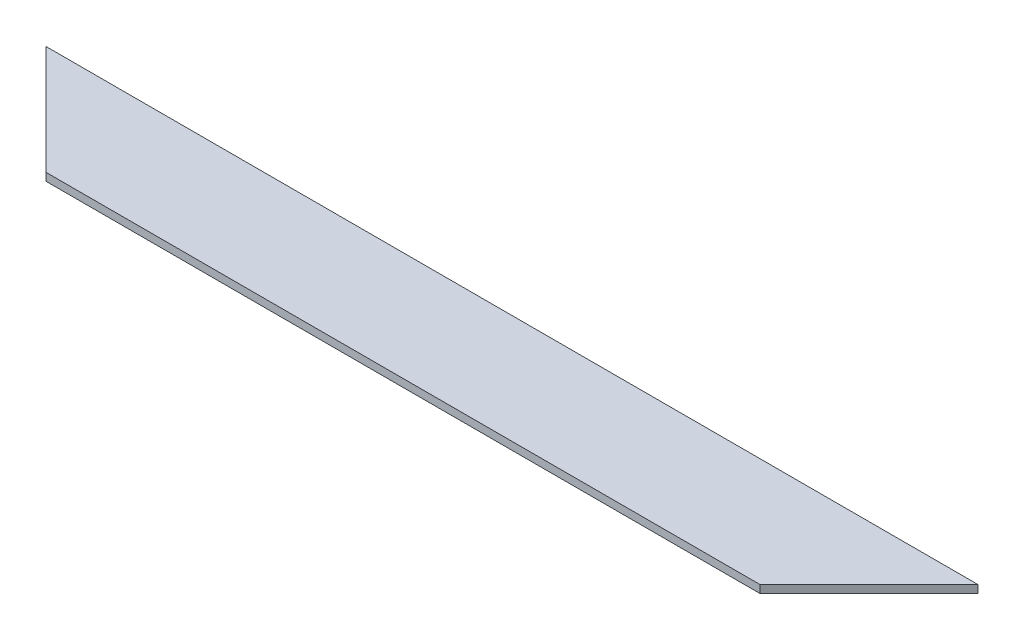
from build123d import *

# Parameters (mm, degrees)
BOSS_EXTRUDE1_DEPTH = 6.35
CUT_EXTRUDE1_DEPTH  = 609.6


with BuildPart() as part:
    # Sketch1 → Boss-Extrude1 (new body)
    with BuildSketch(Plane(origin=(0, 0, 0), x_dir=(1, 0, 0), z_dir=(0, 1, 0))):
        Polygon((-381, -88.9), (-469.9, 0), (469.9, 0), (381, -88.9), align=None)
    extrude(amount=BOSS_EXTRUDE1_DEPTH)

    # Sketch2 → Cut-Extrude1 (cut)
    with BuildSketch(Plane(origin=(0, 6.35, 0), x_dir=(1, 0, 0), z_dir=(0, 1, 0))):
        Polygon((-380.097438789, 0), (-291.197438789, -88.9), (-381, -88.9), (-469.9, 0), align=None)
    cut_extrude1 = extrude(amount=-CUT_EXTRUDE1_DEPTH, mode=Mode.SUBTRACT)

    # Mirror1: Cut-Extrude1 across plane
    add(cut_extrude1.mirror(Plane(origin=(0, 0, 0), x_dir=(0, 0, 1), z_dir=(1, 0, 0))), mode=Mode.SUBTRACT)


solid = part.part
